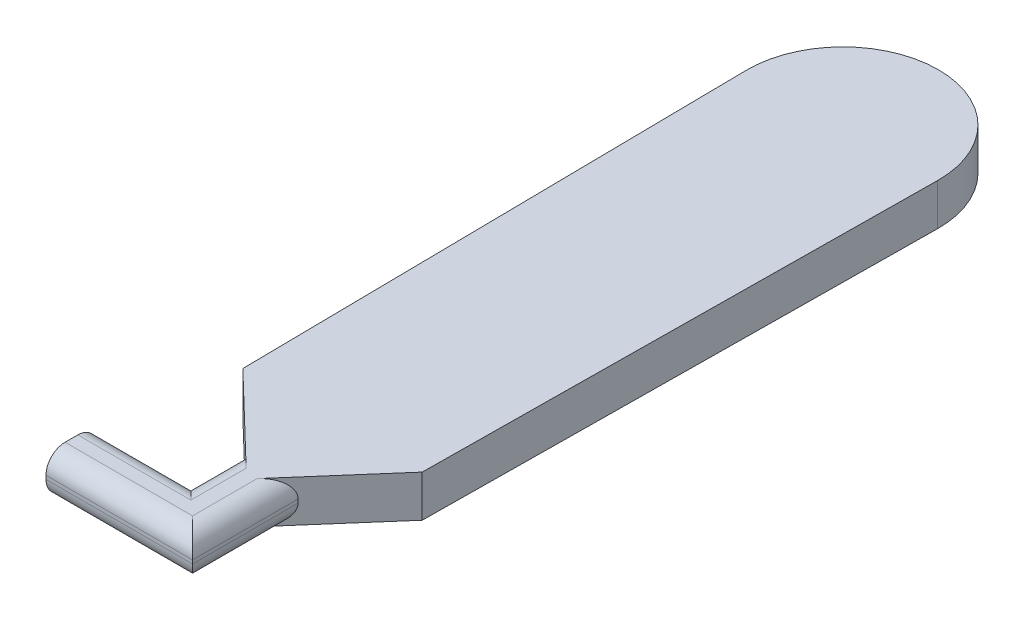
from build123d import *

# Parameters (mm, degrees)
BOSS_EXTRUDE1_DEPTH = 10
FILLET1_R           = 4.572


with BuildPart() as part:
    # Sketch2 → Boss-Extrude1 (new body)
    with BuildSketch(Plane(origin=(0, 0, 0), x_dir=(1, 0, 0), z_dir=(0, 1, 0))):
        with BuildLine():
            Line((6.098836138, 199.947644416), (7.673025909, 77.750683868))
            Line((7.673025909, 77.750683868), (24.192411242, 61.855234605))
            Line((24.192411242, 61.855234605), (24.192411242, 48.766267951))
            Line((24.192411242, 48.766267951), (1.672918099, 48.766267951))
            Line((1.672918099, 48.766267951), (1.672918099, 36.564568547))
            Line((1.672918099, 36.564568547), (36.816624548, 36.564568547))
            Line((36.816624548, 36.564568547), (36.816624548, 61.855234605))
            Line((36.816624548, 61.855234605), (50.677233754, 77.750683868))
            Line((50.677233754, 77.750683868), (51.925307167, 200.008903269))
            ThreePointArc((51.925307167, 200.008903269), (28.981086555, 223.157579607), (6.098836138, 199.947644416))
        make_face()
    extrude(amount=BOSS_EXTRUDE1_DEPTH)

    # Fillet1
    fillet1_edges = [part.edges().sort_by_distance(p)[0] for p in [
        (36.816624548, 0, -49.209901576),
        (19.244771323, 0, -36.564568547),
        (12.932664671, 0, -48.766267951),
        (24.192411242, 0, -55.310751278),
        (24.192411242, 10, -55.310751278),
        (12.932664671, 10, -48.766267951),
        (19.244771323, 10, -36.564568547),
        (36.816624548, 10, -49.209901576),
    ]]
    fillet(fillet1_edges, radius=FILLET1_R)


solid = part.part
